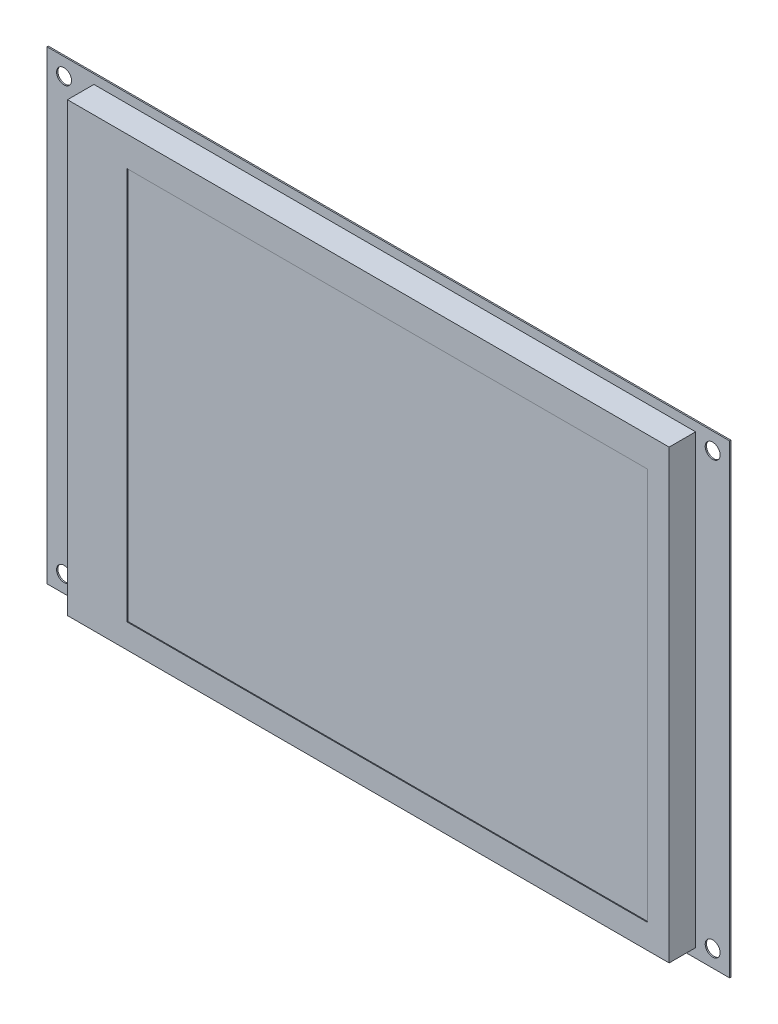
from build123d import *

# Parameters (mm, degrees)
SKETCH1_W          = 141
SKETCH1_H          = 104.7
EXTRUDE1_DEPTH     = 6.2
SKETCH4_W          = 160
SKETCH4_H          = 109
EXTRUDE2_DEPTH     = 0.3
SKETCH5_R          = 1.75
CUT_EXTRUDE1_DEPTH = 0.3
SKETCH3_W          = 122
SKETCH3_H          = 92
CUT_EXTRUDE4_DEPTH = 0.2


with BuildPart() as part:
    # Sketch1 → Extrude1 (new body)
    with BuildSketch(Plane.XY):
        with Locations((70.5, -52.35)):
            Rectangle(SKETCH1_W, SKETCH1_H)
    extrude(amount=EXTRUDE1_DEPTH)

    # Sketch4 → Extrude2 (add)
    with BuildSketch(Plane(origin=(0, 0, 0), x_dir=(-1, 0, 0), z_dir=(0, 0, -1))):
        with Locations((-69, -52.35)):
            Rectangle(SKETCH4_W, SKETCH4_H)
    extrude(amount=EXTRUDE2_DEPTH)

    # Sketch5 → Cut-Extrude1 (cut)
    with BuildSketch(Plane.XY):
        with Locations((145, -1.85)):
            Circle(SKETCH5_R)
        with Locations((145, -102.85)):
            Circle(SKETCH5_R)
        with Locations((-7, -1.85)):
            Circle(SKETCH5_R)
        with Locations((-7, -102.85)):
            Circle(SKETCH5_R)
    extrude(amount=-CUT_EXTRUDE1_DEPTH, mode=Mode.SUBTRACT)

    # Sketch3 → Cut-Extrude4 (cut)
    with BuildSketch(Plane.XY.offset(6.2)):
        with Locations((74.985806668, -52.998526077)):
            Rectangle(SKETCH3_W, SKETCH3_H)
    extrude(amount=-CUT_EXTRUDE4_DEPTH, mode=Mode.SUBTRACT)


solid = part.part
